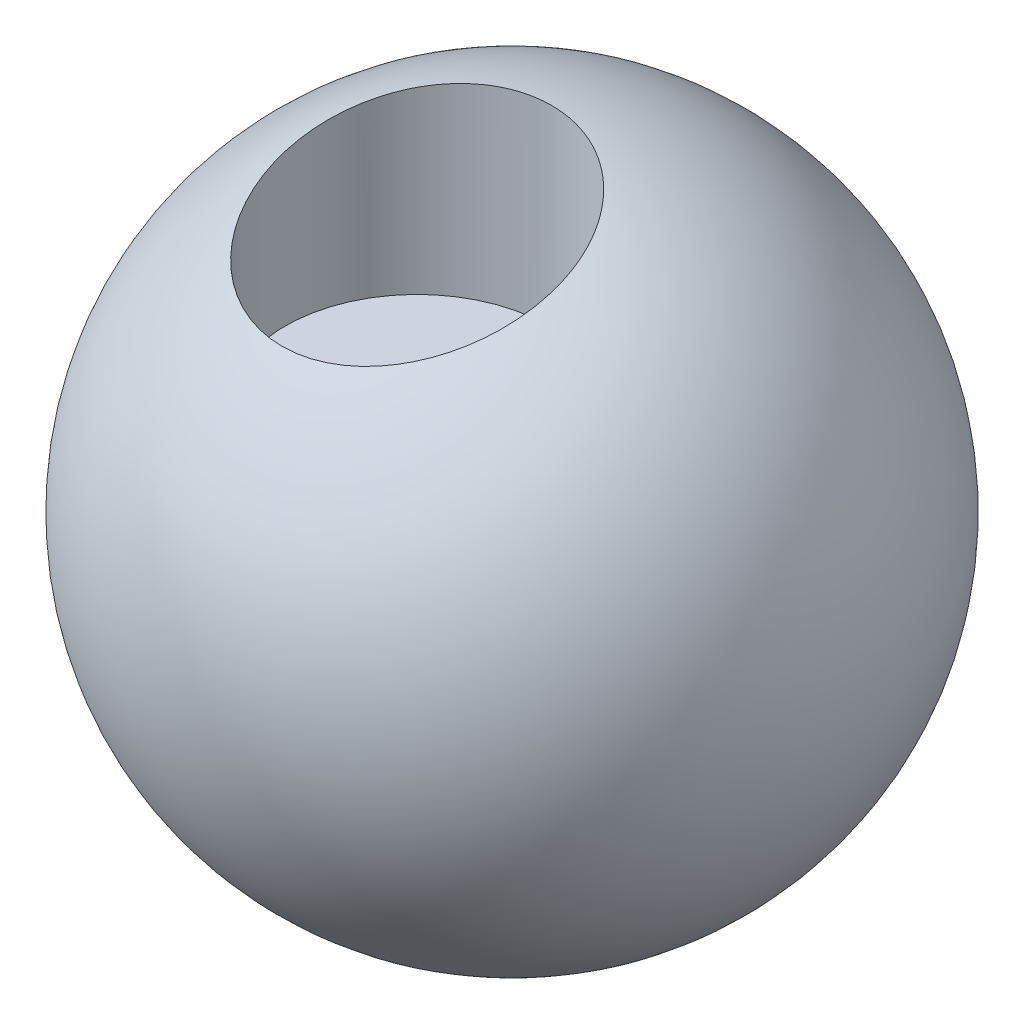
from build123d import *

# Parameters (mm, degrees)
SKETCH6_R          = 40
CUT_EXTRUDE3_DEPTH = 59.294788524860515
SKETCH13_R         = 11.999999999999975
CUT_EXTRUDE7_DEPTH = 65


with BuildPart() as part:
    # Sketch2 → Revolve2 (revolve)
    with BuildSketch(Plane.XY):
        with BuildLine():
            Line((0, 100), (2.776e-14, -100))
            ThreePointArc((2.776e-14, -100), (-100, 1.225e-14), (0, 100))
        make_face()
    revolve(axis=Axis((0, 100, 0), (1.4e-16, -1, 0)))

    # Sketch6 → Cut-Extrude3 (cut)
    with BuildSketch(Plane(origin=(-2.5379788603345292, 100, 26.23220958860291), x_dir=(-1, 0, 0), z_dir=(0, -1, 0))):
        with Locations(Location((0, 0, 0), (0, 0, 139.019257533))):
            Circle(SKETCH6_R)
    extrude(amount=CUT_EXTRUDE3_DEPTH, mode=Mode.SUBTRACT)

    # Sketch13 → Cut-Extrude7 (cut, symmetric)
    with BuildSketch(Plane(origin=(0, 0, 0), x_dir=(0, 0, -1), z_dir=(1, 0, 0))):
        with Locations((60, 0)):
            Circle(SKETCH13_R)
    extrude(amount=CUT_EXTRUDE7_DEPTH, both=True, mode=Mode.SUBTRACT)


solid = part.part
